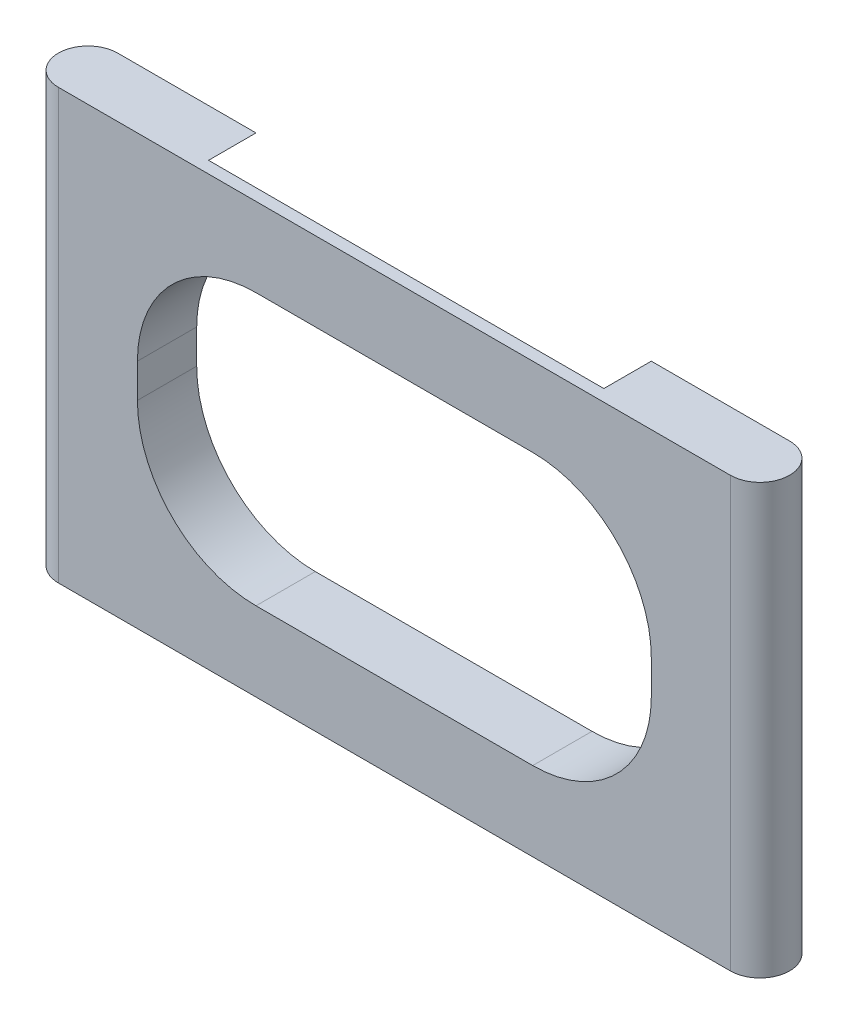
from build123d import *

# Parameters (mm, degrees)
BOSS_EXTRUDE1_DEPTH = 117.6
CUT_EXTRUDE4_DEPTH  = 12
CUT_EXTRUDE6_DEPTH  = 151.36957804
CUT_EXTRUDE7_DEPTH  = 4.5
CUT_EXTRUDE8_START  = 113.1
CUT_EXTRUDE8_DEPTH  = 4.5
CUT_EXTRUDE9_DEPTH  = 4.5
CUT_EXTRUDE10_START = 113.1
CUT_EXTRUDE10_DEPTH = 4.5


with BuildPart() as part:
    # Sketch2 → Boss-Extrude1 (new body)
    with BuildSketch(Plane(origin=(0, 0, 0), x_dir=(1, 0, 0), z_dir=(0, 1, 0))):
        with BuildLine():
            Line((85, -7.5), (-85, -7.5))
            ThreePointArc((-85, -7.5), (-92.5, 0), (-85, 7.5))
            Line((-85, 7.5), (85, 7.5))
            ThreePointArc((85, 7.5), (92.5, 0), (85, -7.5))
        make_face()
    extrude(amount=BOSS_EXTRUDE1_DEPTH)

    # Sketch3 → Cut-Extrude4 (cut)
    with BuildSketch(Plane(origin=(0, 0, -7.5), x_dir=(-1, 0, 0), z_dir=(0, 0, -1))):
        with BuildLine():
            Line((-50, 113.1), (50, 113.1))
            ThreePointArc((50, 113.1), (74.748737342, 102.848737342), (85, 78.1))
            Line((85, 78.1), (85, 39.5))
            ThreePointArc((85, 39.5), (74.748737342, 14.751262658), (50, 4.5))
            Line((50, 4.5), (-50, 4.5))
            ThreePointArc((-50, 4.5), (-74.748737342, 14.751262658), (-85, 39.5))
            Line((-85, 39.5), (-85, 78.1))
            ThreePointArc((-85, 78.1), (-74.748737342, 102.848737342), (-50, 113.1))
        make_face()
        with BuildLine():
            Line((-70, 63.1), (-70, 54.5))
            ThreePointArc((-70, 54.5), (-59.748737342, 29.751262658), (-35, 19.5))
            Line((-35, 19.5), (35, 19.5))
            ThreePointArc((35, 19.5), (59.748737342, 29.751262658), (70, 54.5))
            Line((70, 54.5), (70, 63.1))
            ThreePointArc((70, 63.1), (59.748737342, 87.848737342), (35, 98.1))
            Line((35, 98.1), (-35, 98.1))
            ThreePointArc((-35, 98.1), (-59.748737342, 87.848737342), (-70, 63.1))
        make_face(mode=Mode.SUBTRACT)
    extrude(amount=-CUT_EXTRUDE4_DEPTH, mode=Mode.SUBTRACT)

    # Sketch6 → Cut-Extrude6 (cut, through all)
    with BuildSketch(Plane(origin=(0, 0, -7.5), x_dir=(-1, 0, 0), z_dir=(0, 0, -1))):
        with BuildLine():
            Line((-35, 24.5), (35, 24.5))
            ThreePointArc((35, 24.5), (56.213203436, 33.286796564), (65, 54.5))
            Line((65, 54.5), (65, 63.1))
            ThreePointArc((65, 63.1), (56.213203436, 84.313203436), (35, 93.1))
            Line((35, 93.1), (-35, 93.1))
            ThreePointArc((-35, 93.1), (-56.213203436, 84.313203436), (-65, 63.1))
            Line((-65, 63.1), (-65, 54.5))
            ThreePointArc((-65, 54.5), (-56.213203436, 33.286796564), (-35, 24.5))
        make_face()
    extrude(amount=-CUT_EXTRUDE6_DEPTH, mode=Mode.SUBTRACT)

    # Sketch2_6 → Cut-Extrude7 (cut)
    with BuildSketch(Plane(origin=(0, 0, 0), x_dir=(1, 0, 0), z_dir=(0, 1, 0))):
        with BuildLine():
            Line((-8.2248772, -2.5), (8.2248772, -2.5))
            Line((8.2248772, -2.5), (15.34156858, -1.994983292))
            ThreePointArc((15.34156858, -1.994983292), (17.2, 0), (15.34156858, 1.994983292))
            Line((15.34156858, 1.994983292), (1.88348082, 2.95))
            ThreePointArc((1.88348082, 2.95), (0, 3.5), (-1.88348082, 2.95))
            Line((-1.88348082, 2.95), (-15.34156858, 1.994983292))
            ThreePointArc((-15.34156858, 1.994983292), (-17.2, 0), (-15.34156858, -1.994983292))
            Line((-15.34156858, -1.994983292), (-8.2248772, -2.5))
        make_face()
        with BuildLine():
            Line((1.88348082, -2.95), (8.2248772, -2.5))
            Line((8.2248772, -2.5), (-8.2248772, -2.5))
            Line((-8.2248772, -2.5), (-1.88348082, -2.95))
            ThreePointArc((-1.88348082, -2.95), (0, -3.5), (1.88348082, -2.95))
        make_face()
    extrude(amount=CUT_EXTRUDE7_DEPTH, mode=Mode.SUBTRACT)

    # Sketch2_7 → Cut-Extrude8 (cut)
    with BuildSketch(Plane(origin=(0, 0, 0), x_dir=(1, 0, 0), z_dir=(0, 1, 0)).offset(CUT_EXTRUDE8_START)):
        with BuildLine():
            Line((-8.2248772, -2.5), (8.2248772, -2.5))
            Line((8.2248772, -2.5), (15.34156858, -1.994983292))
            ThreePointArc((15.34156858, -1.994983292), (17.2, 0), (15.34156858, 1.994983292))
            Line((15.34156858, 1.994983292), (1.88348082, 2.95))
            ThreePointArc((1.88348082, 2.95), (0, 3.5), (-1.88348082, 2.95))
            Line((-1.88348082, 2.95), (-15.34156858, 1.994983292))
            ThreePointArc((-15.34156858, 1.994983292), (-17.2, 0), (-15.34156858, -1.994983292))
            Line((-15.34156858, -1.994983292), (-8.2248772, -2.5))
        make_face()
        with BuildLine():
            Line((1.88348082, -2.95), (8.2248772, -2.5))
            Line((8.2248772, -2.5), (-8.2248772, -2.5))
            Line((-8.2248772, -2.5), (-1.88348082, -2.95))
            ThreePointArc((-1.88348082, -2.95), (0, -3.5), (1.88348082, -2.95))
        make_face()
    extrude(amount=CUT_EXTRUDE8_DEPTH, mode=Mode.SUBTRACT)

    # Sketch2_8 → Cut-Extrude9 (cut)
    with BuildSketch(Plane(origin=(0, 0, 0), x_dir=(1, 0, 0), z_dir=(0, 1, 0))):
        with BuildLine():
            Line((85, -2.5), (85, 7.5))
            Line((85, 7.5), (-85, 7.5))
            Line((-85, 7.5), (-85, -2.5))
            Line((-85, -2.5), (-8.2248772, -2.5))
            Line((-8.2248772, -2.5), (-15.34156858, -1.994983292))
            ThreePointArc((-15.34156858, -1.994983292), (-17.2, 0), (-15.34156858, 1.994983292))
            Line((-15.34156858, 1.994983292), (-1.88348082, 2.95))
            ThreePointArc((-1.88348082, 2.95), (0, 3.5), (1.88348082, 2.95))
            Line((1.88348082, 2.95), (15.34156858, 1.994983292))
            ThreePointArc((15.34156858, 1.994983292), (17.2, 0), (15.34156858, -1.994983292))
            Line((15.34156858, -1.994983292), (8.2248772, -2.5))
            Line((8.2248772, -2.5), (85, -2.5))
        make_face()
        with BuildLine():
            Line((70, -7.5), (85, -7.5))
            ThreePointArc((85, -7.5), (92.5, 0), (85, 7.5))
            Line((85, 7.5), (85, -2.5))
            Line((85, -2.5), (8.2248772, -2.5))
            Line((8.2248772, -2.5), (1.88348082, -2.95))
            ThreePointArc((1.88348082, -2.95), (0, -3.5), (-1.88348082, -2.95))
            Line((-1.88348082, -2.95), (-8.2248772, -2.5))
            Line((-8.2248772, -2.5), (-85, -2.5))
            Line((-85, -2.5), (-85, 7.5))
            ThreePointArc((-85, 7.5), (-92.5, 0), (-85, -7.5))
            Line((-85, -7.5), (-70, -7.5))
            Line((-70, -7.5), (-55, -7.5))
            Line((-55, -7.5), (55, -7.5))
            Line((55, -7.5), (70, -7.5))
        make_face()
        with BuildLine():
            Line((1.88348082, -2.95), (8.2248772, -2.5))
            Line((8.2248772, -2.5), (-8.2248772, -2.5))
            Line((-8.2248772, -2.5), (-1.88348082, -2.95))
            ThreePointArc((-1.88348082, -2.95), (0, -3.5), (1.88348082, -2.95))
        make_face()
    extrude(amount=CUT_EXTRUDE9_DEPTH, mode=Mode.SUBTRACT)

    # Sketch2_9 → Cut-Extrude10 (cut)
    with BuildSketch(Plane(origin=(0, 0, 0), x_dir=(1, 0, 0), z_dir=(0, 1, 0)).offset(CUT_EXTRUDE10_START)):
        with BuildLine():
            Line((85, -2.5), (85, 7.5))
            Line((85, 7.5), (-85, 7.5))
            Line((-85, 7.5), (-85, -2.5))
            Line((-85, -2.5), (-8.2248772, -2.5))
            Line((-8.2248772, -2.5), (-15.34156858, -1.994983292))
            ThreePointArc((-15.34156858, -1.994983292), (-17.2, 0), (-15.34156858, 1.994983292))
            Line((-15.34156858, 1.994983292), (-1.88348082, 2.95))
            ThreePointArc((-1.88348082, 2.95), (0, 3.5), (1.88348082, 2.95))
            Line((1.88348082, 2.95), (15.34156858, 1.994983292))
            ThreePointArc((15.34156858, 1.994983292), (17.2, 0), (15.34156858, -1.994983292))
            Line((15.34156858, -1.994983292), (8.2248772, -2.5))
            Line((8.2248772, -2.5), (85, -2.5))
        make_face()
        with BuildLine():
            Line((70, -7.5), (85, -7.5))
            ThreePointArc((85, -7.5), (92.5, 0), (85, 7.5))
            Line((85, 7.5), (85, -2.5))
            Line((85, -2.5), (8.2248772, -2.5))
            Line((8.2248772, -2.5), (1.88348082, -2.95))
            ThreePointArc((1.88348082, -2.95), (0, -3.5), (-1.88348082, -2.95))
            Line((-1.88348082, -2.95), (-8.2248772, -2.5))
            Line((-8.2248772, -2.5), (-85, -2.5))
            Line((-85, -2.5), (-85, 7.5))
            ThreePointArc((-85, 7.5), (-92.5, 0), (-85, -7.5))
            Line((-85, -7.5), (-70, -7.5))
            Line((-70, -7.5), (-55, -7.5))
            Line((-55, -7.5), (55, -7.5))
            Line((55, -7.5), (70, -7.5))
        make_face()
        with BuildLine():
            Line((-8.2248772, -2.5), (8.2248772, -2.5))
            Line((8.2248772, -2.5), (15.34156858, -1.994983292))
            ThreePointArc((15.34156858, -1.994983292), (17.2, 0), (15.34156858, 1.994983292))
            Line((15.34156858, 1.994983292), (1.88348082, 2.95))
            ThreePointArc((1.88348082, 2.95), (0, 3.5), (-1.88348082, 2.95))
            Line((-1.88348082, 2.95), (-15.34156858, 1.994983292))
            ThreePointArc((-15.34156858, 1.994983292), (-17.2, 0), (-15.34156858, -1.994983292))
            Line((-15.34156858, -1.994983292), (-8.2248772, -2.5))
        make_face()
        with BuildLine():
            Line((1.88348082, -2.95), (8.2248772, -2.5))
            Line((8.2248772, -2.5), (-8.2248772, -2.5))
            Line((-8.2248772, -2.5), (-1.88348082, -2.95))
            ThreePointArc((-1.88348082, -2.95), (0, -3.5), (1.88348082, -2.95))
        make_face()
    extrude(amount=CUT_EXTRUDE10_DEPTH, mode=Mode.SUBTRACT)


solid = part.part
